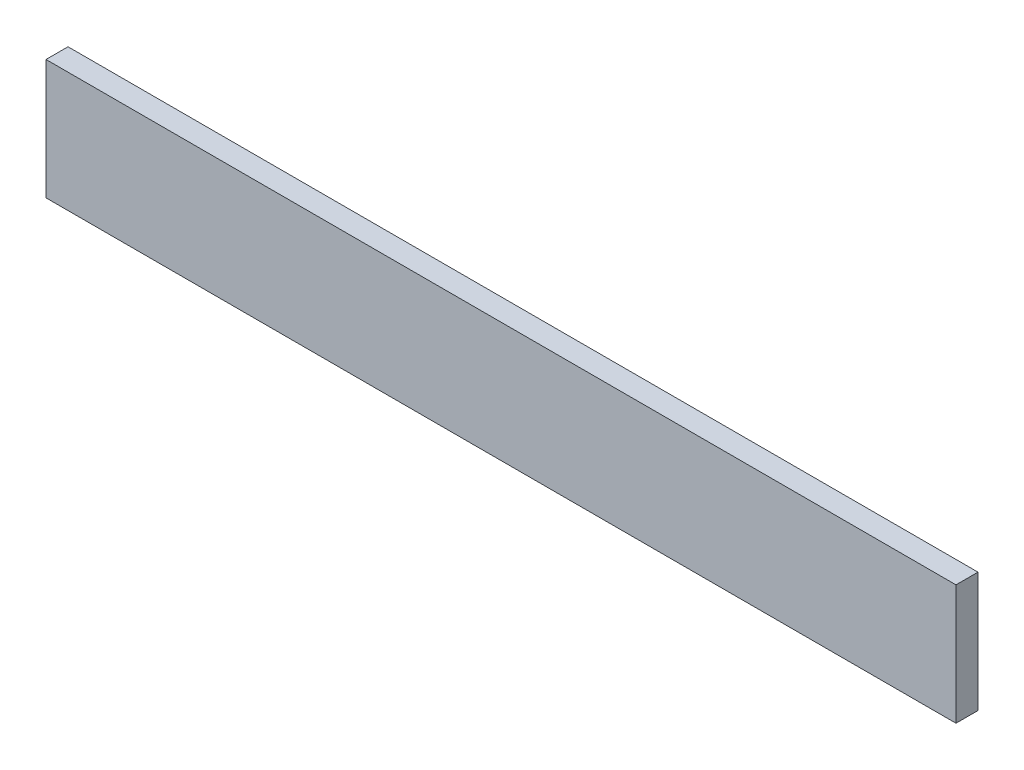
from build123d import *

# Parameters (mm, degrees)
SKETCH1_W           = 744
SKETCH1_H           = 98
BOSS_EXTRUDE1_DEPTH = 18


with BuildPart() as part:
    # Sketch1 → Boss-Extrude1 (new body)
    with BuildSketch(Plane.XY):
        Rectangle(SKETCH1_W, SKETCH1_H)
    extrude(amount=BOSS_EXTRUDE1_DEPTH)


solid = part.part
